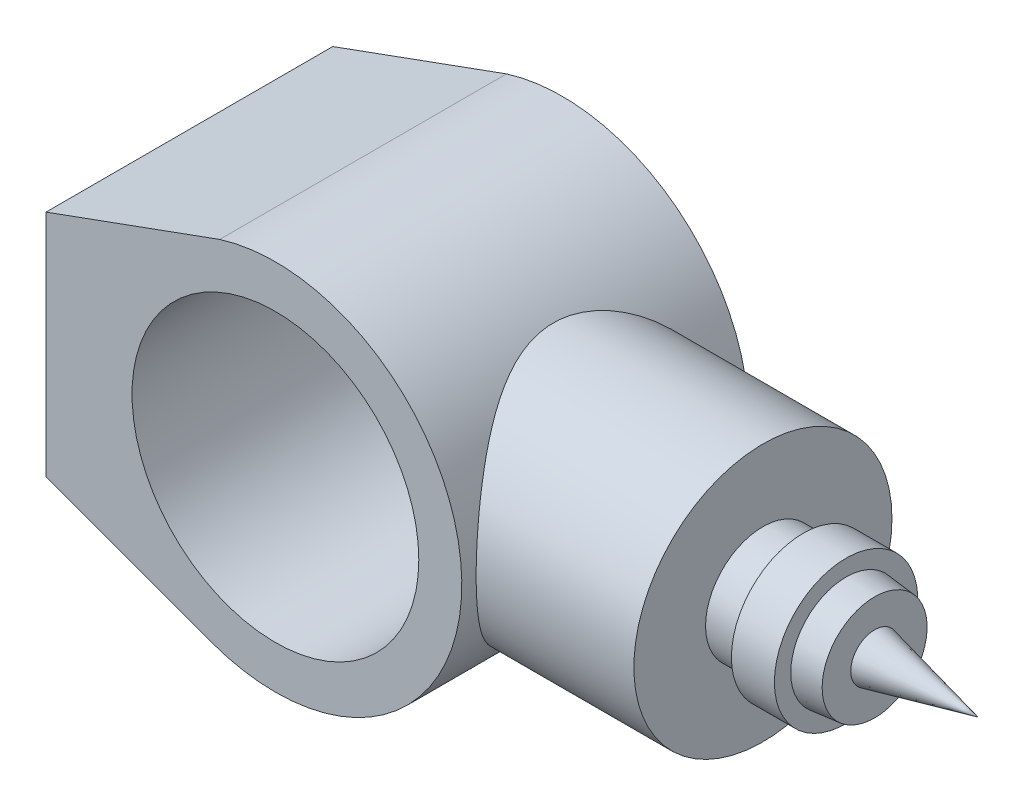
from build123d import *

# Parameters (mm, degrees)
SKETCH1_R           = 50
BOSS_EXTRUDE1_DEPTH = 50
BOSS_EXTRUDE2_REACH = 202
SKETCH2_R           = 45


with BuildPart() as part:
    # Sketch1 → Boss-Extrude1 (new body, symmetric)
    with BuildSketch(Plane.XY):
        with BuildLine():
            Line((-80, -40), (-80, 40))
            Line((-80, 40), (-19.421277332, 62.030750332))
            ThreePointArc((-19.421277332, 62.030750332), (64.982457362, -1.51004478), (-22.281665693, -61.061668614))
            Line((-22.281665693, -61.061668614), (-80, -40))
        make_face()
        Circle(SKETCH1_R, mode=Mode.SUBTRACT)
    extrude(amount=BOSS_EXTRUDE1_DEPTH, both=True)

    # Sketch2 → Boss-Extrude2 (add, up to next)
    with BuildSketch(Plane(origin=(120, 0, 0), x_dir=(0, 0, -1), z_dir=(1, 0, 0)), mode=Mode.PRIVATE) as boss_extrude2_sk1:
        Circle(SKETCH2_R)
    boss_extrude2_tool1 = extrude(boss_extrude2_sk1.sketch, amount=-BOSS_EXTRUDE2_REACH, mode=Mode.PRIVATE) - part.part
    add(boss_extrude2_tool1.solids().sort_by_distance((120, 0, 0))[0])

    # Sketch3 → Revolve1 (revolve)
    with BuildSketch(Plane.XY):
        Polygon((120, 0), (120, -20), (134, -20), (134, -25), (149, -25), (149, -19.298257311), (158.95018422, -18.301345082), (158.95018422, -8.331313354), (195, 0), align=None)
    revolve(axis=Axis((0, 0, 0), (1, 0, 0)))


solid = part.part
